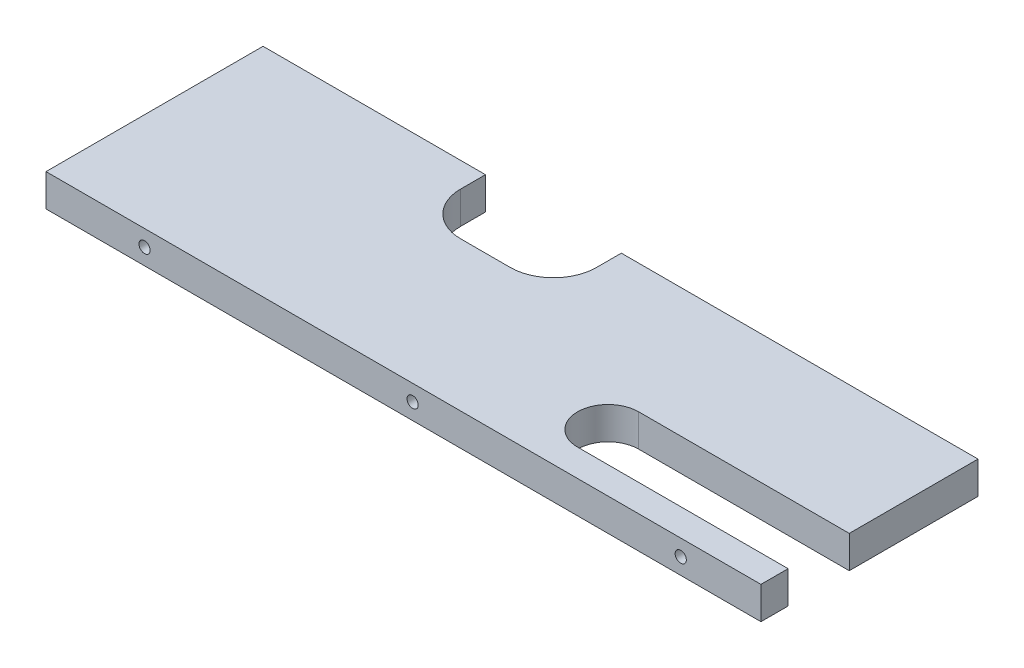
from build123d import *

# Parameters (mm, degrees)
SKETCH1_W                   = 210.475
SKETCH1_H                   = 9.525
BOSS_EXTRUDE1_DEPTH         = 63.9
SKETCH2_W                   = 40
SKETCH2_H                   = 20
CUT_EXTRUDE1_DEPTH          = 10.525
FILLET1_R                   = 12.7
TAP_DRILL_FOR_M4_TAP1_D     = 3.3
TAP_DRILL_FOR_M4_TAP1_DEPTH = 12.7
TAP_DRILL_FOR_M4_TAP1_TIP   = 0.991420021
CUT_EXTRUDE2_DEPTH          = 10.525


with BuildPart() as part:
    # Sketch1 → Boss-Extrude1 (new body)
    with BuildSketch(Plane.XY):
        Rectangle(SKETCH1_W, SKETCH1_H)
    extrude(amount=BOSS_EXTRUDE1_DEPTH)

    # Sketch2 → Cut-Extrude1 (cut, through all)
    with BuildSketch(Plane(origin=(0, 4.7625, 0), x_dir=(1, 0, 0), z_dir=(0, 1, 0))):
        with Locations((-19.7625, -10)):
            Rectangle(SKETCH2_W, SKETCH2_H)
    extrude(amount=-CUT_EXTRUDE1_DEPTH, mode=Mode.SUBTRACT)

    # Fillet1
    fillet1_edges = [part.edges().sort_by_distance(p)[0] for p in [
        (-39.7625, 0, 20),
        (0.2375, 0, 20),
    ]]
    fillet(fillet1_edges, radius=FILLET1_R)

    # Tap Drill for M4 Tap1
    with Locations(Plane.XY.offset(63.9)):
        with Locations((-76.2285, 0), (2.6995, 0), (81.6285, 0)):
            Hole(TAP_DRILL_FOR_M4_TAP1_D / 2, depth=TAP_DRILL_FOR_M4_TAP1_DEPTH)
            with Locations((0, 0, -(TAP_DRILL_FOR_M4_TAP1_DEPTH + TAP_DRILL_FOR_M4_TAP1_TIP / 2))):  # 118° drill point
                Cone(0, TAP_DRILL_FOR_M4_TAP1_D / 2, TAP_DRILL_FOR_M4_TAP1_TIP, mode=Mode.SUBTRACT)

    # Sketch7 → Cut-Extrude2 (cut, through all)
    with BuildSketch(Plane(origin=(0, 4.7625, 0), x_dir=(1, 0, 0), z_dir=(0, 1, 0))):
        with BuildLine():
            Line((43.2375, -37.9), (105.2375, -37.9))
            Line((105.2375, -37.9), (105.2375, -55.9))
            Line((105.2375, -55.9), (43.2375, -55.9))
            ThreePointArc((43.2375, -55.9), (34.2375, -46.9), (43.2375, -37.9))
        make_face()
    extrude(amount=-CUT_EXTRUDE2_DEPTH, mode=Mode.SUBTRACT)


solid = part.part
